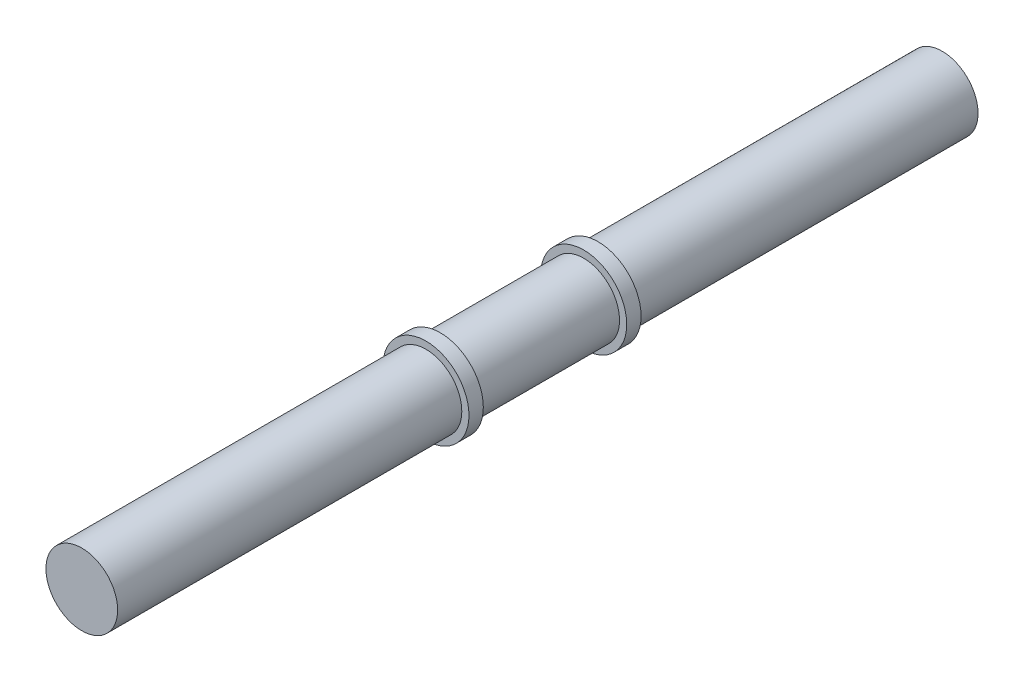
from build123d import *

# Parameters (mm, degrees)
SKETCH1_R           = 5
BOSS_EXTRUDE1_DEPTH = 191.48
SKETCH2_R           = 6
BOSS_EXTRUDE2_DEPTH = 2
SKETCH3_R           = 5
CUT_EXTRUDE1_DEPTH  = 35.74
SKETCH4_R           = 5
CUT_EXTRUDE2_DEPTH  = 35.74


with BuildPart() as part:
    # Sketch1 → Boss-Extrude1 (new body)
    with BuildSketch(Plane.XY):
        Circle(SKETCH1_R)
    extrude(amount=BOSS_EXTRUDE1_DEPTH)

    # Sketch2 → Boss-Extrude2 (add)
    with BuildSketch(Plane.XY.offset(105.74)):
        Circle(SKETCH2_R)
    boss_extrude2 = extrude(amount=BOSS_EXTRUDE2_DEPTH)

    # Mirror1: Boss-Extrude2 across plane
    add(boss_extrude2.mirror(Plane.XY.offset(95.74)))

    # Sketch3 → Cut-Extrude1 (cut)
    with BuildSketch(Plane.XY.offset(191.48)):
        Circle(SKETCH3_R)
    extrude(amount=-CUT_EXTRUDE1_DEPTH, mode=Mode.SUBTRACT)

    # Sketch4 → Cut-Extrude2 (cut)
    with BuildSketch(Plane(origin=(0, 0, 0), x_dir=(-1, 0, 0), z_dir=(0, 0, -1))):
        Circle(SKETCH4_R)
    extrude(amount=-CUT_EXTRUDE2_DEPTH, mode=Mode.SUBTRACT)


solid = part.part
